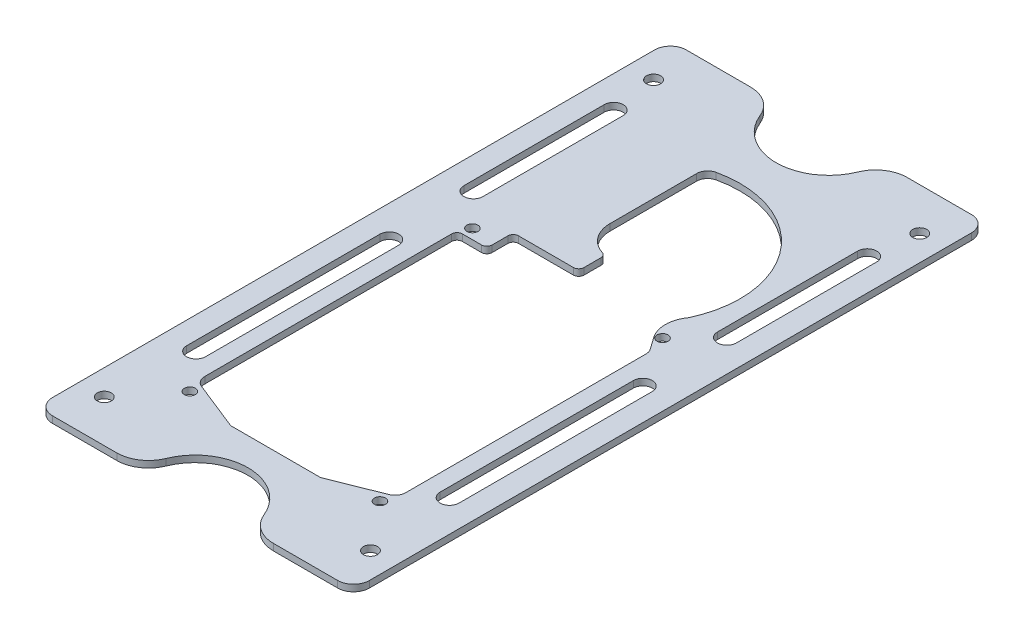
from build123d import *

# Parameters (mm, degrees)
SKETCH1_W           = 152.4
SKETCH1_H           = 304.8
BOSS_EXTRUDE1_DEPTH = 1.5875
SKETCH3_R           = 2.6543
SKETCH3_R_2         = 3.3782
CUT_EXTRUDE1_DEPTH  = 4.175
FILLET1_R           = 7.62
CUT_EXTRUDE2_START  = -4.175
CUT_EXTRUDE2_DEPTH  = 5.175
CUT_EXTRUDE3_DEPTH  = 4.175
CUT_EXTRUDE4_DEPTH  = 4.175


with BuildPart() as part:
    # Sketch1 → Boss-Extrude1 (new body, symmetric)
    with BuildSketch(Plane(origin=(0, 0, 0), x_dir=(1, 0, 0), z_dir=(0, 1, 0))):
        Rectangle(SKETCH1_W, SKETCH1_H)
    extrude(amount=BOSS_EXTRUDE1_DEPTH, both=True)

    # Sketch3 → Cut-Extrude1 (cut, through all)
    with BuildSketch(Plane(origin=(0, 1.5875, 0), x_dir=(1, 0, 0), z_dir=(0, 1, 0))):
        with Locations((45.72, -109.22)):
            Circle(SKETCH3_R)
        with Locations((45.72, 26.67)):
            Circle(SKETCH3_R)
        with Locations((64.008, 132.08)):
            Circle(SKETCH3_R_2)
        with Locations((64.008, -132.08)):
            Circle(SKETCH3_R_2)
    cut_extrude1 = extrude(amount=-CUT_EXTRUDE1_DEPTH, mode=Mode.SUBTRACT)

    # Mirror1: Cut-Extrude1 across plane
    add(cut_extrude1.mirror(Plane(origin=(0, 0, 0), x_dir=(0, 0, 1), z_dir=(1, 0, 0))), mode=Mode.SUBTRACT)

    # Fillet1
    fillet1_edges = [part.edges().sort_by_distance(p)[0] for p in [
        (76.2, 0, 152.4),
        (-76.2, 0, 152.4),
        (-76.2, 0, -152.4),
        (76.2, 0, -152.4),
    ]]
    fillet(fillet1_edges, radius=FILLET1_R)

    # Sketch4 → Cut-Extrude2 (cut)
    with BuildSketch(Plane(origin=(0, 1.5875, 0), x_dir=(1, 0, 0), z_dir=(0, 1, 0)).offset(CUT_EXTRUDE2_START)):
        with BuildLine():
            Line((-753.455657881, 152.4), (-68.58, 152.4))
            Line((-68.58, 152.4), (-37.674288314, 152.4))
            ThreePointArc((-37.674288314, 152.4), (-29.15486932, 149.796340451), (-23.546430197, 142.875))
            ThreePointArc((-23.546430197, 142.875), (0, 127), (23.546430197, 142.875))
            ThreePointArc((23.546430197, 142.875), (29.15486932, 149.796340451), (37.674288314, 152.4))
            Line((37.674288314, 152.4), (68.58, 152.4))
            Line((68.58, 152.4), (753.455657881, 152.4))
            Line((753.455657881, 152.4), (753.455657881, 1522.151315762))
            Line((753.455657881, 1522.151315762), (-753.455657881, 1522.151315762))
            Line((-753.455657881, 1522.151315762), (-753.455657881, 152.4))
        make_face()
    cut_extrude2 = extrude(amount=CUT_EXTRUDE2_DEPTH, mode=Mode.SUBTRACT)

    # Mirror2: Cut-Extrude2 across plane
    add(cut_extrude2.mirror(Plane.XY), mode=Mode.SUBTRACT)

    # Sketch7 → Cut-Extrude3 (cut, through all)
    with BuildSketch(Plane(origin=(0, 1.5875, 0), x_dir=(1, 0, 0), z_dir=(0, 1, 0))):
        with BuildLine():
            Line((65.518901805, 109.877508821), (65.518901805, 42.4057621))
            ThreePointArc((65.518901805, 42.4057621), (60.96, 37.846860295), (56.401098195, 42.4057621))
            Line((56.401098195, 42.4057621), (56.401098195, 109.877508821))
            ThreePointArc((56.401098195, 109.877508821), (60.96, 114.436410627), (65.518901805, 109.877508821))
        make_face()
        with BuildLine():
            Line((65.518901805, 1.973635461), (65.518901805, -90.990364539))
            ThreePointArc((65.518901805, -90.990364539), (60.96, -95.549266345), (56.401098195, -90.990364539))
            Line((56.401098195, -90.990364539), (56.401098195, 1.973635461))
            ThreePointArc((56.401098195, 1.973635461), (60.96, 6.532537266), (65.518901805, 1.973635461))
        make_face()
    cut_extrude3 = extrude(amount=-CUT_EXTRUDE3_DEPTH, mode=Mode.SUBTRACT)

    # Mirror3: Cut-Extrude3 across plane
    add(cut_extrude3.mirror(Plane(origin=(0, 0, 0), x_dir=(0, 0, 1), z_dir=(1, 0, 0))), mode=Mode.SUBTRACT)

    # Sketch9 → Cut-Extrude4 (cut, through all)
    with BuildSketch(Plane.XZ.offset(1.5875)):
        with BuildLine():
            Line((-14.5923, -61.722), (-14.5923, -103.398249639))
            ThreePointArc((-14.5923, -103.398249639), (-13.42547703, -106.718929839), (-10.437940285, -108.579848169))
            ThreePointArc((-10.437940285, -108.579848169), (37.40844001, -91.808826826), (43.529723769, -41.479181989))
            ThreePointArc((43.529723769, -41.479181989), (40.754786716, -33.137895831), (43.391609306, -24.751925581))
            Line((43.391609306, -24.751925581), (47.393812046, -19.116690889))
            ThreePointArc((47.393812046, -19.116690889), (48.123241377, -17.656049777), (48.3743, -16.042820352))
            Line((48.3743, -16.042820352), (48.3743, 99.374229362))
            ThreePointArc((48.3743, 99.374229362), (47.460552946, 102.351896493), (45.03387068, 104.304496914))
            Line((45.03387068, 104.304496914), (21.617623949, 113.6523))
            Line((21.617623949, 113.6523), (-21.617623949, 113.6523))
            Line((-21.617623949, 113.6523), (-45.03387068, 104.304496914))
            ThreePointArc((-45.03387068, 104.304496914), (-47.460552946, 102.351896493), (-48.3743, 99.374229362))
            Line((-48.3743, 99.374229362), (-48.3743, -19.388666667))
            ThreePointArc((-48.3743, -19.388666667), (-47.630351224, -21.184717891), (-45.8343, -21.928666667))
            Line((-45.8343, -21.928666667), (-36.576, -21.928666667))
            ThreePointArc((-36.576, -21.928666667), (-34.779948776, -22.672615442), (-34.036, -24.468666667))
            Line((-34.036, -24.468666667), (-34.036, -32.088666667))
            ThreePointArc((-34.036, -32.088666667), (-33.292051224, -33.884717891), (-31.496, -34.628666667))
            Line((-31.496, -34.628666667), (-5.08, -34.628666667))
            ThreePointArc((-5.08, -34.628666667), (-3.283948776, -35.372615442), (-2.54, -37.168666667))
            Line((-2.54, -37.168666667), (-2.54, -45.360175429))
            ThreePointArc((-2.54, -45.360175429), (-3.034932492, -46.866594656), (-4.326849518, -47.785946307))
            ThreePointArc((-4.326849518, -47.785946307), (-11.748912833, -53.06762154), (-14.5923, -61.722))
        make_face()
    extrude(amount=-CUT_EXTRUDE4_DEPTH, mode=Mode.SUBTRACT)


solid = part.part
